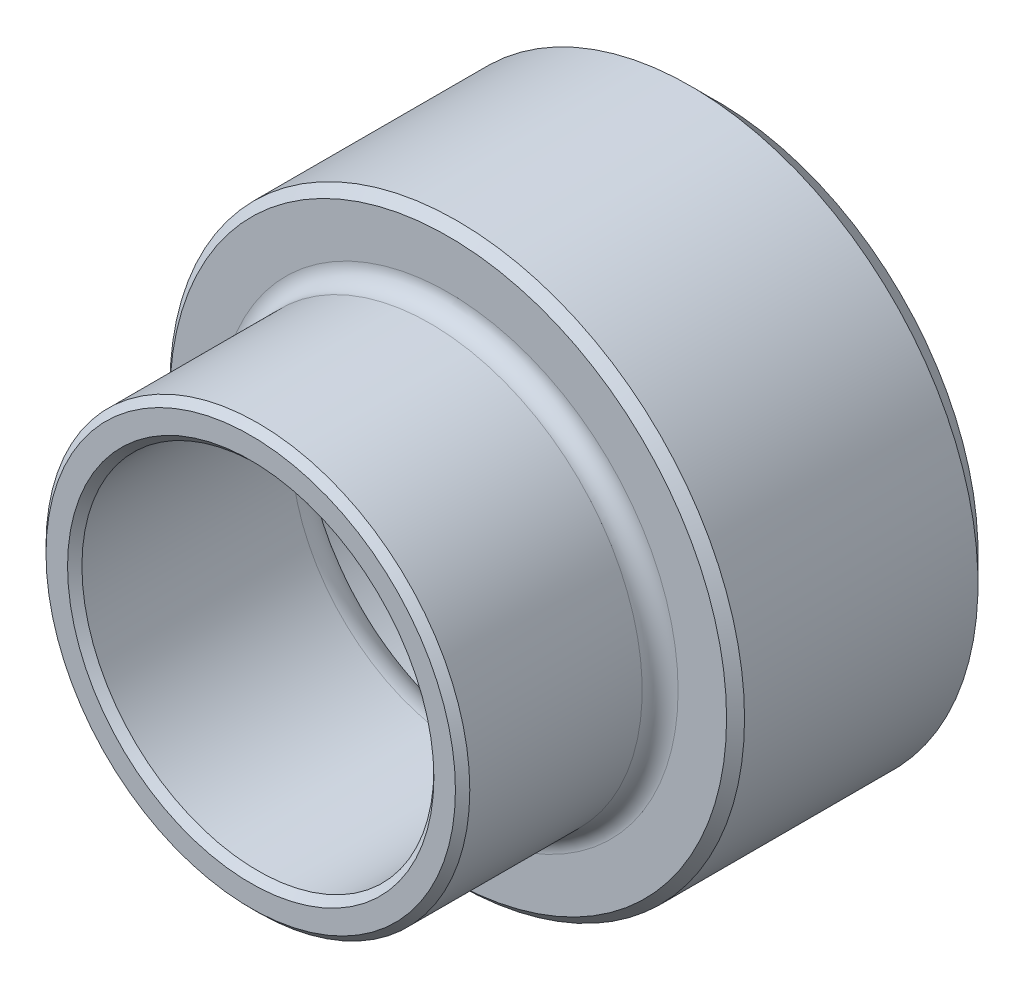
from build123d import *

# Parameters (mm, degrees)
F_12_0_12_DIAMETER_HOLE1_D     = 12
F_12_0_12_DIAMETER_HOLE1_DEPTH = 5.75
F_12_0_12_DIAMETER_HOLE1_TIP   = 3.605163714
CHAMFER1_SIZE                  = 0.75
CHAMFER2_SIZE                  = 0.25
CHAMFER3_SIZE                  = 0.2
FILLET1_R                      = 1


with BuildPart() as part:
    # Sketch1 → Revolve1 (revolve)
    with BuildSketch(Plane.XZ):
        with BuildLine():
            Line((5.9, 13), (4.9, 13))
            Line((4.9, 13), (4.9, 5.75))
            Line((4.9, 5.75), (0, 5.75))
            Line((0, 5.75), (0, 0))
            Line((0, 0), (8, 0))
            Line((8, 0), (8, 7.5))
            Line((8, 7.5), (6.4, 7.5))
            ThreePointArc((6.4, 7.5), (6.046446609, 7.646446609), (5.9, 8))
            Line((5.9, 8), (5.9, 13))
        make_face()
    revolve(axis=Axis((0, 0, 13), (0, 0, -1)))

    # Ø12.0 (12) Diameter Hole1
    with Locations(Plane(origin=(0, 0, 0), x_dir=(-1, 0, 0), z_dir=(0, 0, -1))):
        with Locations((0, 0)):
            Hole(F_12_0_12_DIAMETER_HOLE1_D / 2, depth=F_12_0_12_DIAMETER_HOLE1_DEPTH)
            with Locations((0, 0, -(F_12_0_12_DIAMETER_HOLE1_DEPTH + F_12_0_12_DIAMETER_HOLE1_TIP / 2))):  # 118° drill point
                Cone(0, F_12_0_12_DIAMETER_HOLE1_D / 2, F_12_0_12_DIAMETER_HOLE1_TIP, mode=Mode.SUBTRACT)

    # Chamfer1
    chamfer1_edges = [part.edges().sort_by_distance(p)[0] for p in [
        (-8, 0, 0),
    ]]
    chamfer(chamfer1_edges, length=CHAMFER1_SIZE)

    # Chamfer2
    chamfer2_edges = [part.edges().sort_by_distance(p)[0] for p in [
        (-8, 0, 7.5),
    ]]
    chamfer(chamfer2_edges, length=CHAMFER2_SIZE)

    # Chamfer3
    chamfer3_edges = [part.edges().sort_by_distance(p)[0] for p in [
        (-6, 0, 0),
        (-5.9, 0, 13),
        (-4.9, 0, 13),
    ]]
    chamfer(chamfer3_edges, length=CHAMFER3_SIZE)

    # Fillet1
    fillet1_edges = [part.edges().sort_by_distance(p)[0] for p in [
        (0, -4.9, 6.410946681),
    ]]
    fillet(fillet1_edges, radius=FILLET1_R)


solid = part.part
